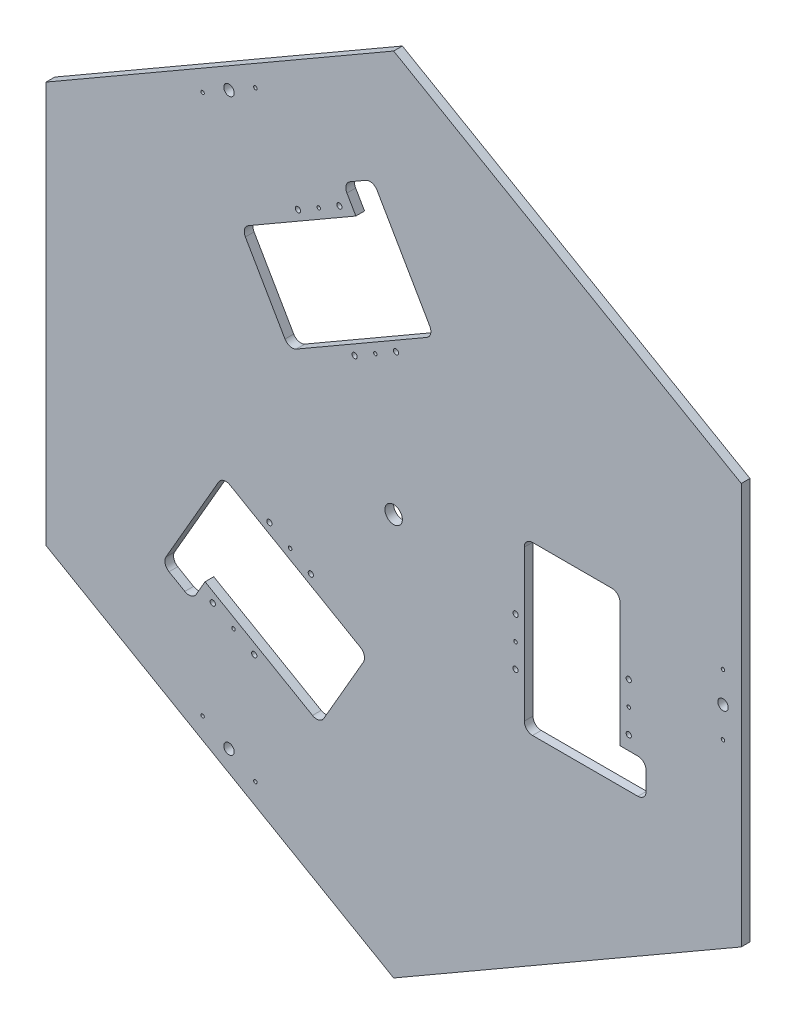
from build123d import *

# Parameters (mm, degrees)
ESQUISSE1_R        = 10
ESQUISSE1_R_2      = 3
ESQUISSE1_R_3      = 2
ESQUISSE1_R_4      = 6
BOSS_EXTRU_1_DEPTH = 10


with BuildPart() as part:
    # Esquisse1 → Boss.-Extru.1 (new body)
    with BuildSketch(Plane.XY):
        Polygon((399.237711145, 230.5), (0, 461), (-399.237711145, 230.5), (-399.237711145, -230.5), (0, -461), (399.237711145, -230.5), align=None)
        Circle(ESQUISSE1_R, mode=Mode.SUBTRACT)
        with Locations((140, -29)):
            Circle(ESQUISSE1_R_2, mode=Mode.SUBTRACT)
        with Locations((140, -56.5)):
            Circle(ESQUISSE1_R_3, mode=Mode.SUBTRACT)
        with Locations((140, -84)):
            Circle(ESQUISSE1_R_2, mode=Mode.SUBTRACT)
        with Locations((378.237711145, 0)):
            Circle(ESQUISSE1_R_4, mode=Mode.SUBTRACT)
        with Locations((378.237711145, 35)):
            Circle(ESQUISSE1_R_3, mode=Mode.SUBTRACT)
        with Locations((378.237711145, -35)):
            Circle(ESQUISSE1_R_3, mode=Mode.SUBTRACT)
        with Locations((270, -84)):
            Circle(ESQUISSE1_R_2, mode=Mode.SUBTRACT)
        with Locations((270, -56.5)):
            Circle(ESQUISSE1_R_3, mode=Mode.SUBTRACT)
        with Locations((270, -29)):
            Circle(ESQUISSE1_R_2, mode=Mode.SUBTRACT)
        with Locations((-95.11473671, -106.74355653)):
            Circle(ESQUISSE1_R_2, mode=Mode.SUBTRACT)
        with Locations((-118.930435314, -92.99355653)):
            Circle(ESQUISSE1_R_3, mode=Mode.SUBTRACT)
        with Locations((-142.746133918, -79.24355653)):
            Circle(ESQUISSE1_R_2, mode=Mode.SUBTRACT)
        with Locations((-207.746133918, -191.826859022)):
            Circle(ESQUISSE1_R_2, mode=Mode.SUBTRACT)
        with Locations((-183.930435314, -205.576859022)):
            Circle(ESQUISSE1_R_3, mode=Mode.SUBTRACT)
        with Locations((-160.11473671, -219.326859022)):
            Circle(ESQUISSE1_R_2, mode=Mode.SUBTRACT)
        with Locations((-189.118855572, -327.563466521)):
            Circle(ESQUISSE1_R_4, mode=Mode.SUBTRACT)
        with Locations((-158.80796644, -345.063466521)):
            Circle(ESQUISSE1_R_3, mode=Mode.SUBTRACT)
        with Locations((-219.429744705, -310.063466521)):
            Circle(ESQUISSE1_R_3, mode=Mode.SUBTRACT)
        with Locations((-44.88526329, 135.74355653)):
            Circle(ESQUISSE1_R_2, mode=Mode.SUBTRACT)
        with Locations((-21.069564686, 149.49355653)):
            Circle(ESQUISSE1_R_3, mode=Mode.SUBTRACT)
        with Locations((2.746133918, 163.24355653)):
            Circle(ESQUISSE1_R_2, mode=Mode.SUBTRACT)
        with Locations((-62.253866082, 275.826859022)):
            Circle(ESQUISSE1_R_2, mode=Mode.SUBTRACT)
        with Locations((-86.069564686, 262.076859022)):
            Circle(ESQUISSE1_R_3, mode=Mode.SUBTRACT)
        with Locations((-109.88526329, 248.326859022)):
            Circle(ESQUISSE1_R_2, mode=Mode.SUBTRACT)
        with Locations((-189.118855572, 327.56346652)):
            Circle(ESQUISSE1_R_4, mode=Mode.SUBTRACT)
        with Locations((-219.429744705, 310.06346652)):
            Circle(ESQUISSE1_R_3, mode=Mode.SUBTRACT)
        with Locations((-158.80796644, 345.06346652)):
            Circle(ESQUISSE1_R_3, mode=Mode.SUBTRACT)
        with BuildLine():
            Line((150, 42.5), (150, -130.5))
            ThreePointArc((150, -130.5), (152.782485579, -137.217514421), (159.5, -140))
            Line((159.5, -140), (280.5, -140))
            ThreePointArc((280.5, -140), (287.217514421, -137.217514421), (290, -130.5))
            Line((290, -130.5), (290, -109.5))
            ThreePointArc((290, -109.5), (287.217514421, -102.782485579), (280.5, -100))
            Line((280.5, -100), (260, -100))
            Line((260, -100), (260, 42.5))
            ThreePointArc((260, 42.5), (257.217514421, 49.217514421), (250.5, 52))
            Line((250.5, 52), (159.5, 52))
            ThreePointArc((159.5, 52), (152.782485579, 49.217514421), (150, 42.5))
        make_face(mode=Mode.SUBTRACT)
        with BuildLine():
            Line((-80.216679003, -242.939363648), (-34.716679003, -164.131051904))
            ThreePointArc((-34.716679003, -164.131051904), (-33.767624989, -156.922270975), (-38.193920339, -151.153810568))
            Line((-38.193920339, -151.153810568), (-188.016315194, -64.653810568))
            ThreePointArc((-188.016315194, -64.653810568), (-195.225096122, -63.704756554), (-200.99355653, -68.131051904))
            Line((-200.99355653, -68.131051904), (-261.49355653, -172.920125762))
            ThreePointArc((-261.49355653, -172.920125762), (-262.442610544, -180.12890669), (-258.016315194, -185.897367098))
            Line((-258.016315194, -185.897367098), (-239.829781714, -196.397367098))
            ThreePointArc((-239.829781714, -196.397367098), (-232.621000786, -197.346421111), (-226.852540378, -192.920125762))
            Line((-226.852540378, -192.920125762), (-216.602540378, -175.166604984))
            Line((-216.602540378, -175.166604984), (-93.193920339, -246.416604984))
            ThreePointArc((-93.193920339, -246.416604984), (-85.985139411, -247.365658998), (-80.216679003, -242.939363648))
        make_face(mode=Mode.SUBTRACT)
        with BuildLine():
            Line((-170.283320997, 190.939363648), (-124.783320997, 112.131051904))
            ThreePointArc((-124.783320997, 112.131051904), (-119.014860589, 107.704756554), (-111.806079661, 108.653810568))
            Line((-111.806079661, 108.653810568), (38.016315194, 195.153810568))
            ThreePointArc((38.016315194, 195.153810568), (42.442610544, 200.922270975), (41.49355653, 208.131051904))
            Line((41.49355653, 208.131051904), (-19.00644347, 312.920125761))
            ThreePointArc((-19.00644347, 312.920125761), (-24.774903878, 317.346421111), (-31.983684806, 316.397367097))
            Line((-31.983684806, 316.397367097), (-50.170218286, 305.897367097))
            ThreePointArc((-50.170218286, 305.897367097), (-54.596513635, 300.12890669), (-53.647459622, 292.920125761))
            Line((-53.647459622, 292.920125761), (-43.397459622, 275.166604984))
            Line((-43.397459622, 275.166604984), (-166.806079661, 203.916604984))
            ThreePointArc((-166.806079661, 203.916604984), (-171.232375011, 198.148144576), (-170.283320997, 190.939363648))
        make_face(mode=Mode.SUBTRACT)
    extrude(amount=BOSS_EXTRU_1_DEPTH)


solid = part.part
